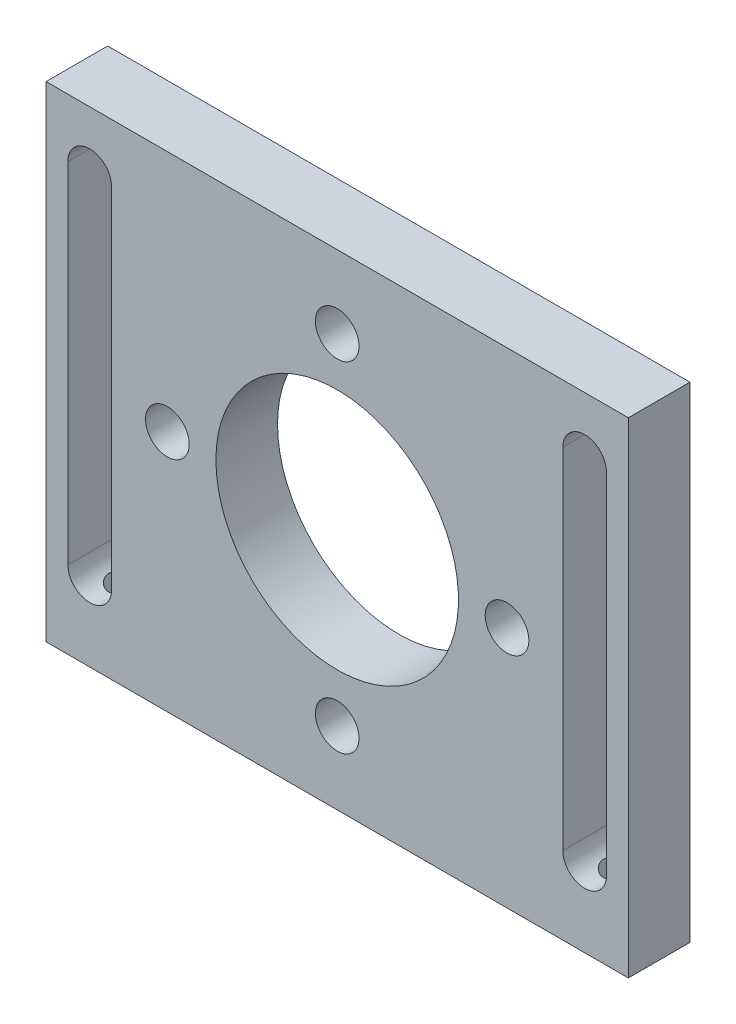
from build123d import *

# Parameters (mm, degrees)
SKETCH1_W                  = 60
SKETCH1_H                  = 50
BOSS_EXTRUDE1_DEPTH        = 6.35
CUT_EXTRUDE1_DEPTH         = 40.564156758
CUT_EXTRUDE2_DEPTH         = 40.564156758
HOLE1_D                    = 25
F_8_CLEARANCE_HOLE1_D      = 4.5
F_2_CLEARANCE_HOLE1_REACH  = 60.654
F_2_CLEARANCE_HOLE1_BORE_R = 1.25
CHAMFER1_SIZE              = 2.45


with BuildPart() as part:
    # Sketch1 → Boss-Extrude1 (new body)
    with BuildSketch(Plane(origin=(0, 0, 0), x_dir=(-1, 0, 0), z_dir=(0, 0, -1))):
        Rectangle(SKETCH1_W, SKETCH1_H)
    extrude(amount=-BOSS_EXTRUDE1_DEPTH)

    # Sketch2 → Cut-Extrude1 (cut, through all)
    with BuildSketch(Plane(origin=(0, 0, 0), x_dir=(-1, 0, 0), z_dir=(0, 0, -1))):
        with BuildLine():
            Line((23.25, 19), (23.25, -17))
            ThreePointArc((23.25, -17), (25.5, -19.25), (27.75, -17))
            Line((27.75, -17), (27.75, 19))
            ThreePointArc((27.75, 19), (25.5, 21.25), (23.25, 19))
        make_face()
    extrude(amount=-CUT_EXTRUDE1_DEPTH, mode=Mode.SUBTRACT)

    # Sketch3 → Cut-Extrude2 (cut, through all)
    with BuildSketch(Plane.XY.offset(6.35)):
        with BuildLine():
            Line((27.75, -17), (27.75, 19))
            ThreePointArc((27.75, 19), (25.5, 21.25), (23.25, 19))
            Line((23.25, 19), (23.25, -17))
            ThreePointArc((23.25, -17), (25.5, -19.25), (27.75, -17))
        make_face()
    extrude(amount=-CUT_EXTRUDE2_DEPTH, mode=Mode.SUBTRACT)

    # Hole1 (through all)
    with Locations(Plane(origin=(0, 0, 0), x_dir=(-1, 0, 0), z_dir=(0, 0, -1))):
        with Locations((0, 0)):
            Hole(HOLE1_D / 2)

    # #8 Clearance Hole1 (through all)
    with Locations(Plane(origin=(0, 0, 0), x_dir=(-1, 0, 0), z_dir=(0, 0, -1))):
        with Locations((0, 17.5), (17.5, 0), (0, -17.5), (-17.5, 0)):
            Hole(F_8_CLEARANCE_HOLE1_D / 2)

    # #2 Clearance Hole1 bore → #2 Clearance Hole1 (cut, up to next)
    with BuildSketch(Plane(origin=(0, -25, 0), x_dir=(-1, 0, 0), z_dir=(0, -1, 0)), mode=Mode.PRIVATE) as f_2_clearance_hole1_sk1:
        with Locations((-25.5, -3.175)):
            Circle(F_2_CLEARANCE_HOLE1_BORE_R)
    f_2_clearance_hole1_tool1 = extrude(f_2_clearance_hole1_sk1.sketch, amount=-F_2_CLEARANCE_HOLE1_REACH, mode=Mode.PRIVATE) & part.part
    # #2 Clearance Hole1 bore → #2 Clearance Hole1 (cut, up to next)
    with BuildSketch(Plane(origin=(0, -25, 0), x_dir=(-1, 0, 0), z_dir=(0, -1, 0)), mode=Mode.PRIVATE) as f_2_clearance_hole1_sk2:
        with Locations((25.5, -3.175)):
            Circle(F_2_CLEARANCE_HOLE1_BORE_R)
    f_2_clearance_hole1_tool2 = extrude(f_2_clearance_hole1_sk2.sketch, amount=-F_2_CLEARANCE_HOLE1_REACH, mode=Mode.PRIVATE) & part.part
    add(f_2_clearance_hole1_tool1.solids().sort_by_distance((25.5, -25, 3.175))[0], mode=Mode.SUBTRACT)
    add(f_2_clearance_hole1_tool2.solids().sort_by_distance((-25.5, -25, 3.175))[0], mode=Mode.SUBTRACT)

    # Chamfer1
    chamfer1_edges = [part.edges().sort_by_distance(p)[0] for p in [
        (15.25, 0, 0),
        (-2.25, -17.5, 0),
        (-19.75, 0, 0),
        (-2.25, 17.5, 0),
    ]]
    chamfer(chamfer1_edges, length=CHAMFER1_SIZE)


solid = part.part
